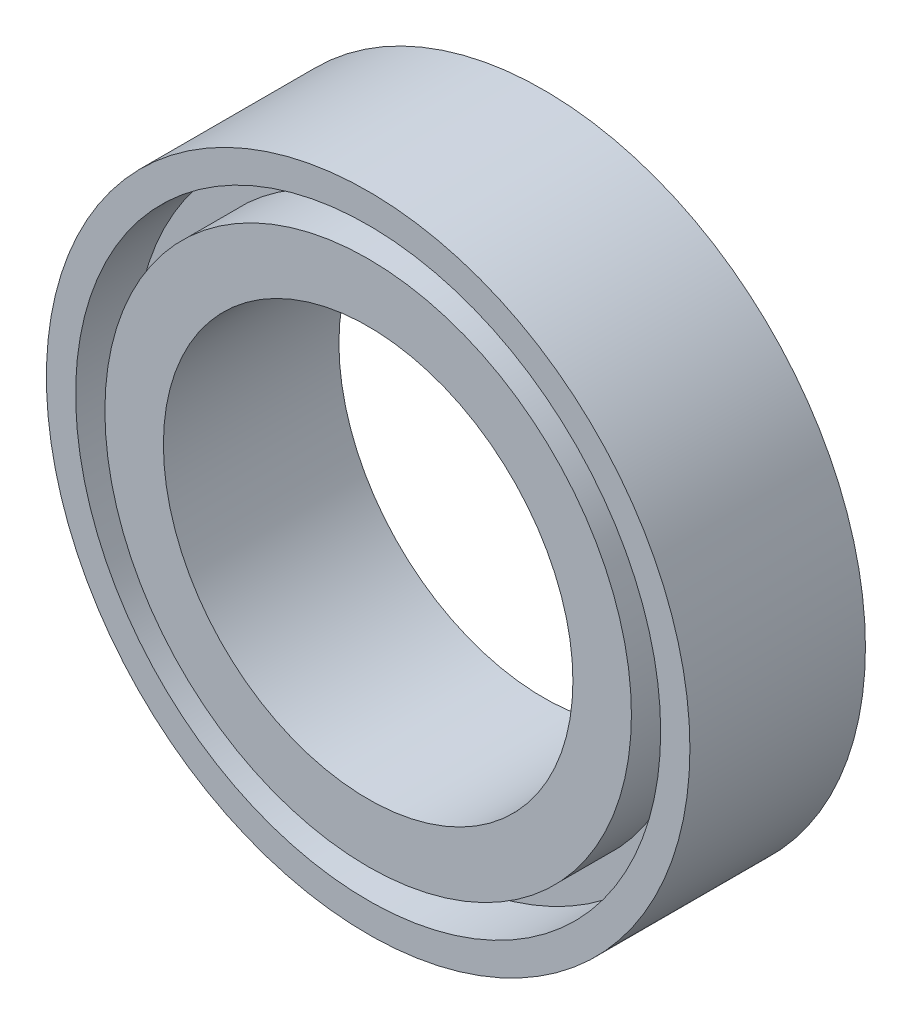
from build123d import *

# Parameters (mm, degrees)
SKETCH_1_R          = 5.5
SKETCH_1_R_2        = 3.5
EXTRUDE_1_DEPTH     = 3
SKETCH_2_R          = 5
SKETCH_2_R_2        = 4.5
CUT_EXTRUDE_1_DEPTH = 1
SKETCH_3_R          = 5
SKETCH_3_R_2        = 4.5
CUT_EXTRUDE_2_DEPTH = 1


with BuildPart() as part:
    # 草图1 → 凸台-拉伸1 (new body)
    with BuildSketch(Plane.XY):
        Circle(SKETCH_1_R)
        Circle(SKETCH_1_R_2, mode=Mode.SUBTRACT)
    extrude(amount=EXTRUDE_1_DEPTH)

    # 草图2 → 切除-拉伸1 (cut)
    with BuildSketch(Plane.XY.offset(3)):
        Circle(SKETCH_2_R)
        Circle(SKETCH_2_R_2, mode=Mode.SUBTRACT)
    extrude(amount=-CUT_EXTRUDE_1_DEPTH, mode=Mode.SUBTRACT)

    # 草图3 → 切除-拉伸2 (cut)
    with BuildSketch(Plane(origin=(0, 0, 0), x_dir=(-1, 0, 0), z_dir=(0, 0, -1))):
        Circle(SKETCH_3_R)
        Circle(SKETCH_3_R_2, mode=Mode.SUBTRACT)
    extrude(amount=-CUT_EXTRUDE_2_DEPTH, mode=Mode.SUBTRACT)


solid = part.part
